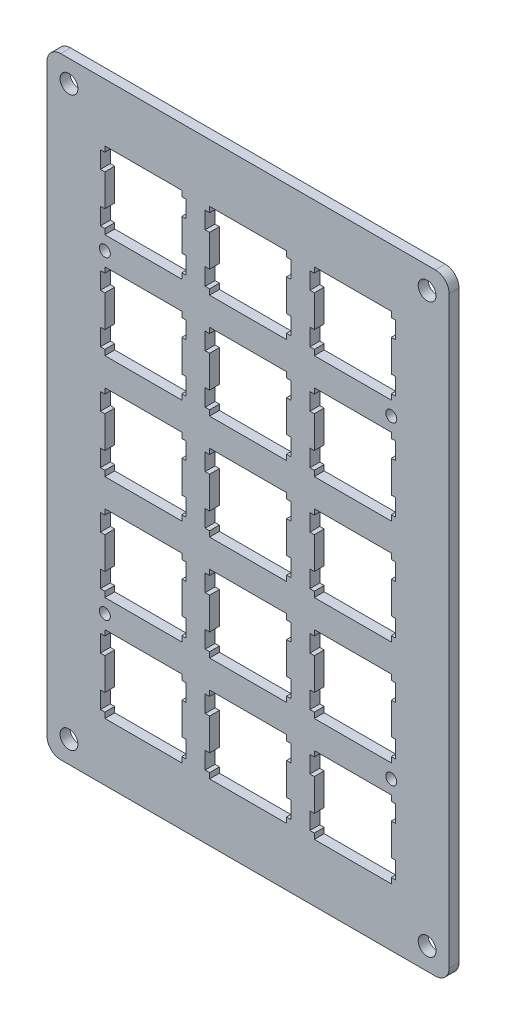
from build123d import *

# Parameters (mm, degrees)
MODEL_R         = 1.625
MODEL_R_2       = 1
EXTRUDE_1_DEPTH = 1.8


with BuildPart() as part:
    # Model → 凸台-拉伸1 (new body)
    with BuildSketch(Plane.XY):
        with BuildLine():
            Line((73.150734615, 2.50028403), (73.150734615, 8.00028403))
            Line((73.150734615, 8.00028403), (73.150734615, 108.75009103))
            ThreePointArc((73.150734615, 108.75009103), (72.418501568, 110.517857983), (70.650734615, 111.25009103))
            Line((70.650734615, 111.25009103), (8.000519215, 111.25009103))
            Line((8.000519215, 111.25009103), (2.500519215, 111.25009103))
            ThreePointArc((2.500519215, 111.25009103), (0.732752263, 110.517857983), (0.000519215, 108.75009103))
            Line((0.000519215, 108.75009103), (0.000519215, 8.00028403))
            Line((0.000519215, 8.00028403), (0.000519215, 2.50028403))
            ThreePointArc((0.000519215, 2.50028403), (0.732752263, 0.732517077), (2.500519215, 0.00028403))
            Line((2.500519215, 0.00028403), (65.150734615, 0.00028403))
            Line((65.150734615, 0.00028403), (70.650734615, 0.00028403))
            ThreePointArc((70.650734615, 0.00028403), (72.418501568, 0.732517077), (73.150734615, 2.50028403))
        make_face()
        with Locations((4.000519215, 4.00028403)):
            Circle(MODEL_R, mode=Mode.SUBTRACT)
        Polygon((10.525084615, 23.52529103), (10.525084615, 24.52569103), (24.524634615, 24.52569103), (24.524634615, 23.52529103), (25.325234615, 23.52529103), (25.325234615, 20.42739103), (24.524634615, 20.42739103), (24.524634615, 14.62588103), (25.325234615, 14.62588103), (25.325234615, 11.52532103), (24.524634615, 11.52532103), (24.524634615, 10.52623103), (10.525084615, 10.52623103), (10.525084615, 11.52532103), (9.724444615, 11.52532103), (9.724444615, 14.62588103), (10.525084615, 14.62588103), (10.525084615, 20.42739103), (9.724444615, 20.42739103), (9.724444615, 23.52529103), align=None, mode=Mode.SUBTRACT)
        with Locations((10.525084615, 27.05094103)):
            Circle(MODEL_R_2, mode=Mode.SUBTRACT)
        Polygon((29.575134615, 23.52529103), (29.575134615, 24.52569103), (43.574434615, 24.52569103), (43.574434615, 23.52529103), (44.375234615, 23.52529103), (44.375234615, 20.42739103), (43.574434615, 20.42739103), (43.574434615, 14.62588103), (44.375234615, 14.62588103), (44.375234615, 11.52532103), (43.574434615, 11.52532103), (43.574434615, 10.52623103), (29.575134615, 10.52623103), (29.575134615, 11.52532103), (28.774434615, 11.52532103), (28.774434615, 14.62588103), (29.575134615, 14.62588103), (29.575134615, 20.42739103), (28.774434615, 20.42739103), (28.774434615, 23.52529103), align=None, mode=Mode.SUBTRACT)
        Polygon((10.525084615, 42.57529103), (10.525084615, 43.57559103), (24.524634615, 43.57559103), (24.524634615, 42.57529103), (25.325234615, 42.57529103), (25.325234615, 39.47739103), (24.524634615, 39.47739103), (24.524634615, 33.67589103), (25.325234615, 33.67589103), (25.325234615, 30.57529103), (24.524634615, 30.57529103), (24.524634615, 29.57619103), (10.525084615, 29.57619103), (10.525084615, 30.57529103), (9.724444615, 30.57529103), (9.724444615, 33.67589103), (10.525084615, 33.67589103), (10.525084615, 39.47739103), (9.724444615, 39.47739103), (9.724444615, 42.57529103), align=None, mode=Mode.SUBTRACT)
        Polygon((29.575134615, 42.57529103), (29.575134615, 43.57559103), (43.574434615, 43.57559103), (43.574434615, 42.57529103), (44.375234615, 42.57529103), (44.375234615, 39.47739103), (43.574434615, 39.47739103), (43.574434615, 33.67589103), (44.375234615, 33.67589103), (44.375234615, 30.57529103), (43.574434615, 30.57529103), (43.574434615, 29.57619103), (29.575134615, 29.57619103), (29.575134615, 30.57529103), (28.774434615, 30.57529103), (28.774434615, 33.67589103), (29.575134615, 33.67589103), (29.575134615, 39.47739103), (28.774434615, 39.47739103), (28.774434615, 42.57529103), align=None, mode=Mode.SUBTRACT)
        with Locations((69.150734615, 4.00028403)):
            Circle(MODEL_R, mode=Mode.SUBTRACT)
        Polygon((48.625134615, 23.52529103), (48.625134615, 24.52569103), (62.624434615, 24.52569103), (62.624434615, 23.52529103), (63.425234615, 23.52529103), (63.425234615, 20.42739103), (62.624434615, 20.42739103), (62.624434615, 14.62588103), (63.425234615, 14.62588103), (63.425234615, 11.52532103), (62.624434615, 11.52532103), (62.624434615, 10.52623103), (48.625134615, 10.52623103), (48.625134615, 11.52532103), (47.824334615, 11.52532103), (47.824334615, 14.62588103), (48.625134615, 14.62588103), (48.625134615, 20.42739103), (47.824334615, 20.42739103), (47.824334615, 23.52529103), align=None, mode=Mode.SUBTRACT)
        with Locations((62.624434615, 27.05094103)):
            Circle(MODEL_R_2, mode=Mode.SUBTRACT)
        Polygon((48.625134615, 42.57529103), (48.625134615, 43.57559103), (62.624434615, 43.57559103), (62.624434615, 42.57529103), (63.425234615, 42.57529103), (63.425234615, 39.47739103), (62.624434615, 39.47739103), (62.624434615, 33.67589103), (63.425234615, 33.67589103), (63.425234615, 30.57529103), (62.624434615, 30.57529103), (62.624434615, 29.57619103), (48.625134615, 29.57619103), (48.625134615, 30.57529103), (47.824334615, 30.57529103), (47.824334615, 33.67589103), (48.625134615, 33.67589103), (48.625134615, 39.47739103), (47.824334615, 39.47739103), (47.824334615, 42.57529103), align=None, mode=Mode.SUBTRACT)
        Polygon((10.525084615, 61.62519103), (10.525084615, 62.62569103), (24.524634615, 62.62569103), (24.524634615, 61.62519103), (25.325234615, 61.62519103), (25.325234615, 58.52599103), (24.524634615, 58.52599103), (24.524634615, 52.72599103), (25.325234615, 52.72599103), (25.325234615, 49.62539103), (24.524634615, 49.62539103), (24.524634615, 48.62639103), (10.525084615, 48.62639103), (10.525084615, 49.62539103), (9.724444615, 49.62539103), (9.724444615, 52.72599103), (10.525084615, 52.72599103), (10.525084615, 58.52599103), (9.724444615, 58.52599103), (9.724444615, 61.62519103), align=None, mode=Mode.SUBTRACT)
        Polygon((24.524634615, 67.67639103), (10.525084615, 67.67639103), (10.525084615, 68.67539103), (9.724444615, 68.67539103), (9.724444615, 71.77599103), (10.525084615, 71.77599103), (10.525084615, 77.57599103), (9.724444615, 77.57599103), (9.724444615, 80.67519103), (10.525084615, 80.67519103), (10.525084615, 81.67569103), (24.524634615, 81.67569103), (24.524634615, 80.67519103), (25.325234615, 80.67519103), (25.325234615, 77.57599103), (24.524634615, 77.57599103), (24.524634615, 71.77599103), (25.325234615, 71.77599103), (25.325234615, 68.67539103), (24.524634615, 68.67539103), align=None, mode=Mode.SUBTRACT)
        Polygon((29.575134615, 61.62519103), (29.575134615, 62.62569103), (43.574434615, 62.62569103), (43.574434615, 61.62519103), (44.375234615, 61.62519103), (44.375234615, 58.52599103), (43.574434615, 58.52599103), (43.574434615, 52.72599103), (44.375234615, 52.72599103), (44.375234615, 49.62539103), (43.574434615, 49.62539103), (43.574434615, 48.62639103), (29.575134615, 48.62639103), (29.575134615, 49.62539103), (28.774434615, 49.62539103), (28.774434615, 52.72599103), (29.575134615, 52.72599103), (29.575134615, 58.52599103), (28.774434615, 58.52599103), (28.774434615, 61.62519103), align=None, mode=Mode.SUBTRACT)
        Polygon((29.575134615, 80.67519103), (29.575134615, 81.67569103), (43.574434615, 81.67569103), (43.574434615, 80.67519103), (44.375234615, 80.67519103), (44.375234615, 77.57599103), (43.574434615, 77.57599103), (43.574434615, 71.77599103), (44.375234615, 71.77599103), (44.375234615, 68.67539103), (43.574434615, 68.67539103), (43.574434615, 67.67639103), (29.575134615, 67.67639103), (29.575134615, 68.67539103), (28.774434615, 68.67539103), (28.774434615, 71.77599103), (29.575134615, 71.77599103), (29.575134615, 77.57599103), (28.774434615, 77.57599103), (28.774434615, 80.67519103), align=None, mode=Mode.SUBTRACT)
        with Locations((10.525084615, 84.20104103)):
            Circle(MODEL_R_2, mode=Mode.SUBTRACT)
        Polygon((10.525084615, 99.72519103), (10.525084615, 100.72569103), (24.524634615, 100.72569103), (24.524634615, 99.72519103), (25.325234615, 99.72519103), (25.325234615, 96.62599103), (24.524634615, 96.62599103), (24.524634615, 90.82599103), (25.325234615, 90.82599103), (25.325234615, 87.72539103), (24.524634615, 87.72539103), (24.524634615, 86.72639103), (10.525084615, 86.72639103), (10.525084615, 87.72539103), (9.724444615, 87.72539103), (9.724444615, 90.82599103), (10.525084615, 90.82599103), (10.525084615, 96.62599103), (9.724444615, 96.62599103), (9.724444615, 99.72519103), align=None, mode=Mode.SUBTRACT)
        with Locations((4.000519215, 107.25009103)):
            Circle(MODEL_R, mode=Mode.SUBTRACT)
        Polygon((29.575134615, 99.72519103), (29.575134615, 100.72569103), (43.574434615, 100.72569103), (43.574434615, 99.72519103), (44.375234615, 99.72519103), (44.375234615, 96.62599103), (43.574434615, 96.62599103), (43.574434615, 90.82599103), (44.375234615, 90.82599103), (44.375234615, 87.72539103), (43.574434615, 87.72539103), (43.574434615, 86.72639103), (29.575134615, 86.72639103), (29.575134615, 87.72539103), (28.774434615, 87.72539103), (28.774434615, 90.82599103), (29.575134615, 90.82599103), (29.575134615, 96.62599103), (28.774434615, 96.62599103), (28.774434615, 99.72519103), align=None, mode=Mode.SUBTRACT)
        Polygon((48.625134615, 61.62519103), (48.625134615, 62.62569103), (62.624434615, 62.62569103), (62.624434615, 61.62519103), (63.425234615, 61.62519103), (63.425234615, 58.52599103), (62.624434615, 58.52599103), (62.624434615, 52.72599103), (63.425234615, 52.72599103), (63.425234615, 49.62539103), (62.624434615, 49.62539103), (62.624434615, 48.62639103), (48.625134615, 48.62639103), (48.625134615, 49.62539103), (47.824334615, 49.62539103), (47.824334615, 52.72599103), (48.625134615, 52.72599103), (48.625134615, 58.52599103), (47.824334615, 58.52599103), (47.824334615, 61.62519103), align=None, mode=Mode.SUBTRACT)
        Polygon((48.625134615, 80.67519103), (48.625134615, 81.67569103), (62.624434615, 81.67569103), (62.624434615, 80.67519103), (63.425234615, 80.67519103), (63.425234615, 77.57599103), (62.624434615, 77.57599103), (62.624434615, 71.77599103), (63.425234615, 71.77599103), (63.425234615, 68.67539103), (62.624434615, 68.67539103), (62.624434615, 67.67639103), (48.625134615, 67.67639103), (48.625134615, 68.67539103), (47.824334615, 68.67539103), (47.824334615, 71.77599103), (48.625134615, 71.77599103), (48.625134615, 77.57599103), (47.824334615, 77.57599103), (47.824334615, 80.67519103), align=None, mode=Mode.SUBTRACT)
        with Locations((62.624434615, 84.20104103)):
            Circle(MODEL_R_2, mode=Mode.SUBTRACT)
        Polygon((48.625134615, 99.72519103), (48.625134615, 100.72569103), (62.624434615, 100.72569103), (62.624434615, 99.72519103), (63.425234615, 99.72519103), (63.425234615, 96.62599103), (62.624434615, 96.62599103), (62.624434615, 90.82599103), (63.425234615, 90.82599103), (63.425234615, 87.72539103), (62.624434615, 87.72539103), (62.624434615, 86.72639103), (48.625134615, 86.72639103), (48.625134615, 87.72539103), (47.824334615, 87.72539103), (47.824334615, 90.82599103), (48.625134615, 90.82599103), (48.625134615, 96.62599103), (47.824334615, 96.62599103), (47.824334615, 99.72519103), align=None, mode=Mode.SUBTRACT)
        with Locations((69.150734615, 107.25009103)):
            Circle(MODEL_R, mode=Mode.SUBTRACT)
    extrude(amount=EXTRUDE_1_DEPTH)


solid = part.part
